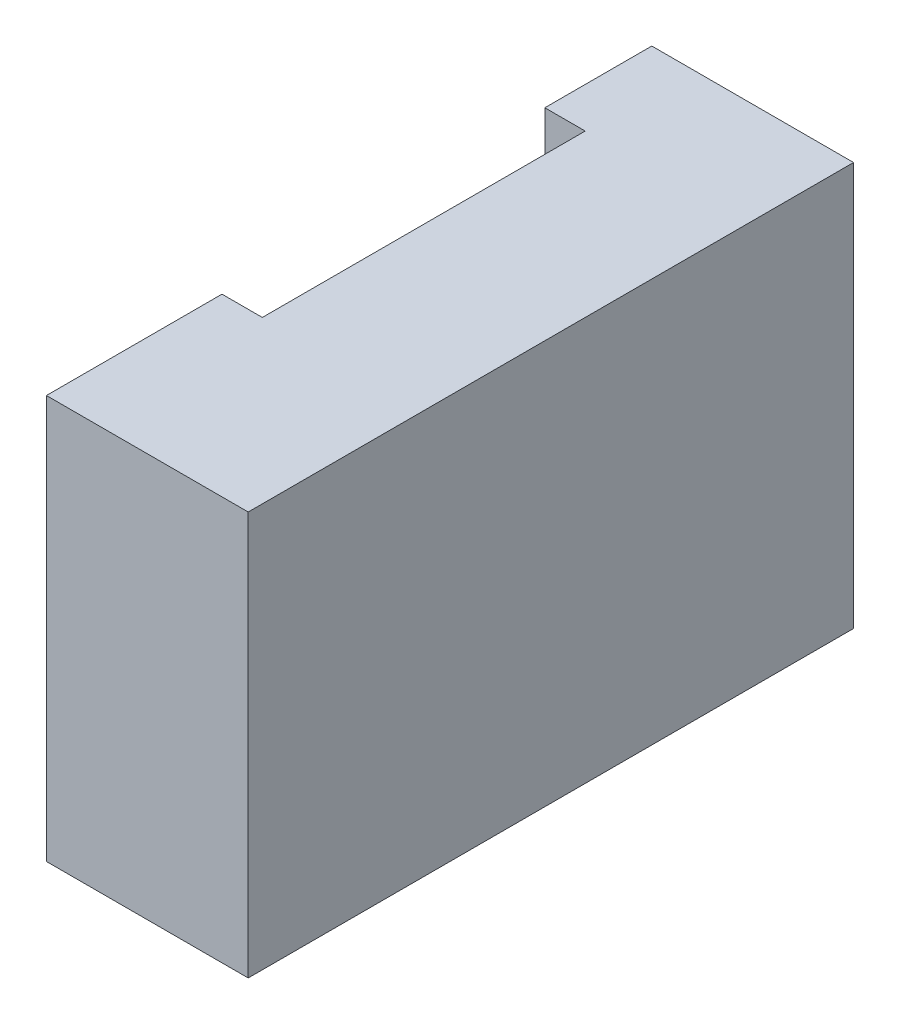
from build123d import *

# Parameters (mm, degrees)
SKETCH1_W           = 5
SKETCH1_H           = 10
BOSS_EXTRUDE1_DEPTH = 7.5
SKETCH4_W           = 1
SKETCH4_H           = 8
CUT_EXTRUDE2_DEPTH  = 11


with BuildPart() as part:
    # Sketch1 → Boss-Extrude1 (new body, symmetric)
    with BuildSketch(Plane.XY):
        Rectangle(SKETCH1_W, SKETCH1_H)
    extrude(amount=BOSS_EXTRUDE1_DEPTH, both=True)

    # Sketch4 → Cut-Extrude2 (cut, through all)
    with BuildSketch(Plane(origin=(0, 5, 0), x_dir=(1, 0, 0), z_dir=(0, 1, 0))):
        with Locations((-2, 0.85)):
            Rectangle(SKETCH4_W, SKETCH4_H)
    extrude(amount=-CUT_EXTRUDE2_DEPTH, mode=Mode.SUBTRACT)


solid = part.part
